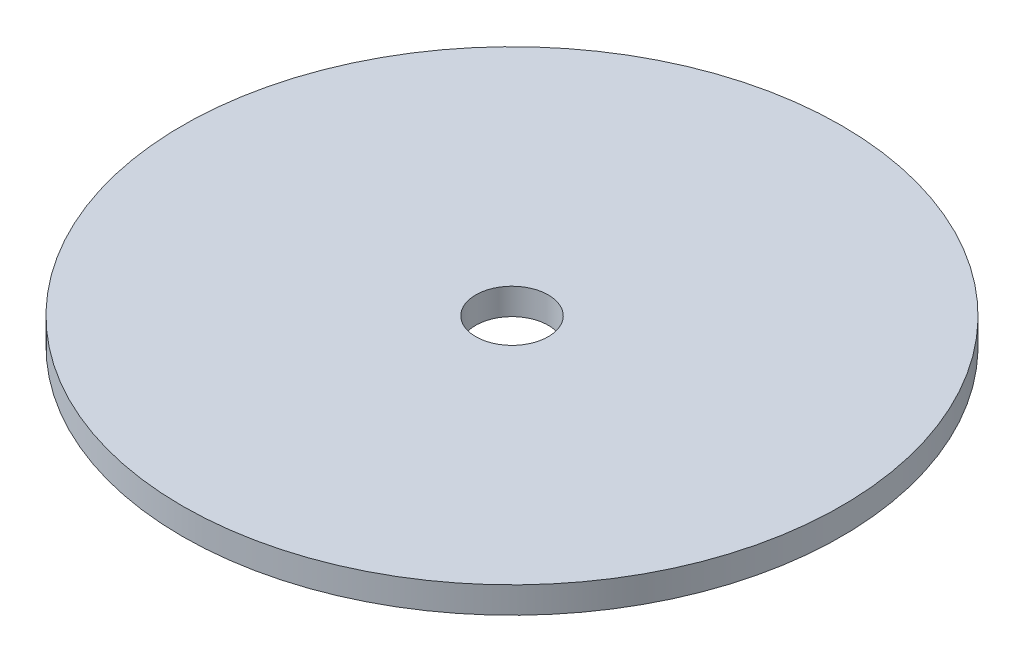
from build123d import *

# Parameters (mm, degrees)
SKETCH1_R           = 37.5
SKETCH1_R_2         = 4.125
BOSS_EXTRUDE1_DEPTH = 3


with BuildPart() as part:
    # Sketch1 → Boss-Extrude1 (new body)
    with BuildSketch(Plane(origin=(0, 0, 0), x_dir=(1, 0, 0), z_dir=(0, 1, 0))):
        Circle(SKETCH1_R)
        Circle(SKETCH1_R_2, mode=Mode.SUBTRACT)
    extrude(amount=BOSS_EXTRUDE1_DEPTH)


solid = part.part
